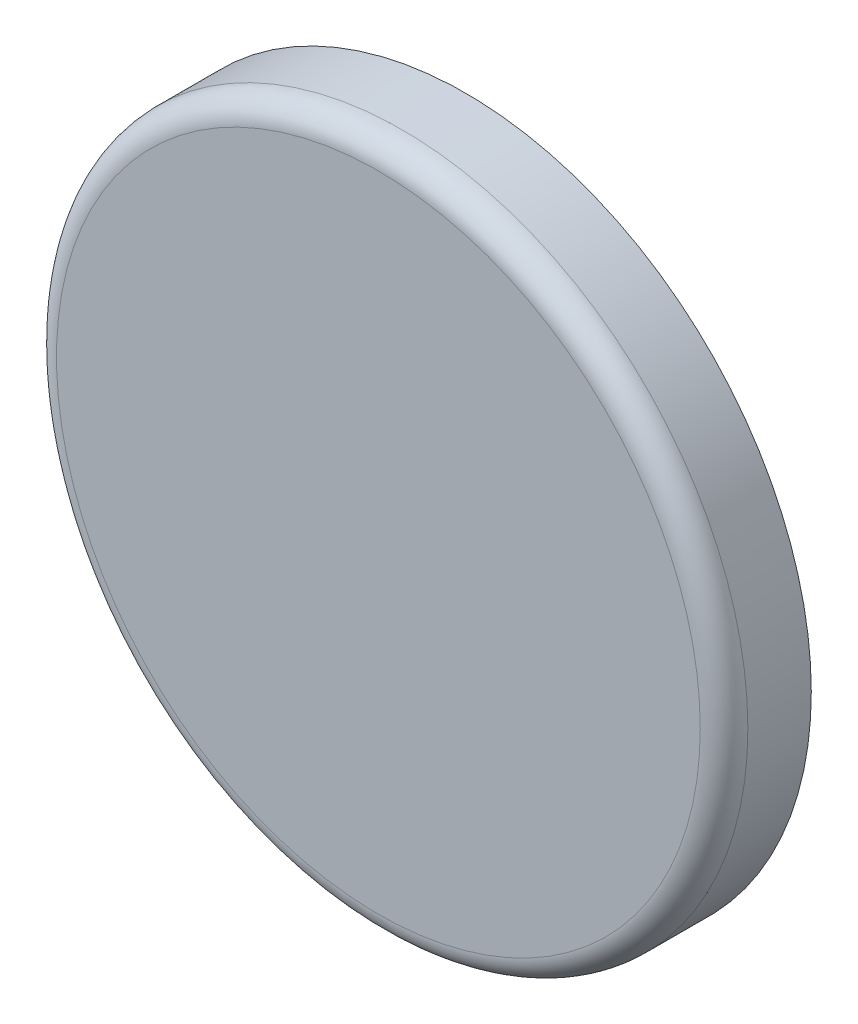
from build123d import *

# Parameters (mm, degrees)
CROQUIS1_R              = 43.5901732
SALIENTE_EXTRUIR1_DEPTH = 11
REDONDEO1_R             = 3
CROQUIS2_R              = 5.875
CORTAR_EXTRUIR1_DEPTH   = 9
CROQUIS3_R              = 7
CORTAR_EXTRUIR2_DEPTH   = 4.5


with BuildPart() as part:
    # Croquis1 → Saliente-Extruir1 (new body)
    with BuildSketch(Plane.XY):
        Circle(CROQUIS1_R)
    extrude(amount=SALIENTE_EXTRUIR1_DEPTH)

    # Redondeo1
    redondeo1_edges = [part.edges().sort_by_distance(p)[0] for p in [
        (-43.5901732, 0, 11),
    ]]
    fillet(redondeo1_edges, radius=REDONDEO1_R)

    # Croquis2 → Cortar-Extruir1 (cut)
    with BuildSketch(Plane(origin=(0, 0, 0), x_dir=(-1, 0, 0), z_dir=(0, 0, -1))):
        Circle(CROQUIS2_R)
    extrude(amount=-CORTAR_EXTRUIR1_DEPTH, mode=Mode.SUBTRACT)

    # Croquis3 → Cortar-Extruir2 (cut)
    with BuildSketch(Plane(origin=(0, 0, 0), x_dir=(-1, 0, 0), z_dir=(0, 0, -1))):
        Circle(CROQUIS3_R)
    extrude(amount=-CORTAR_EXTRUIR2_DEPTH, mode=Mode.SUBTRACT)


solid = part.part
